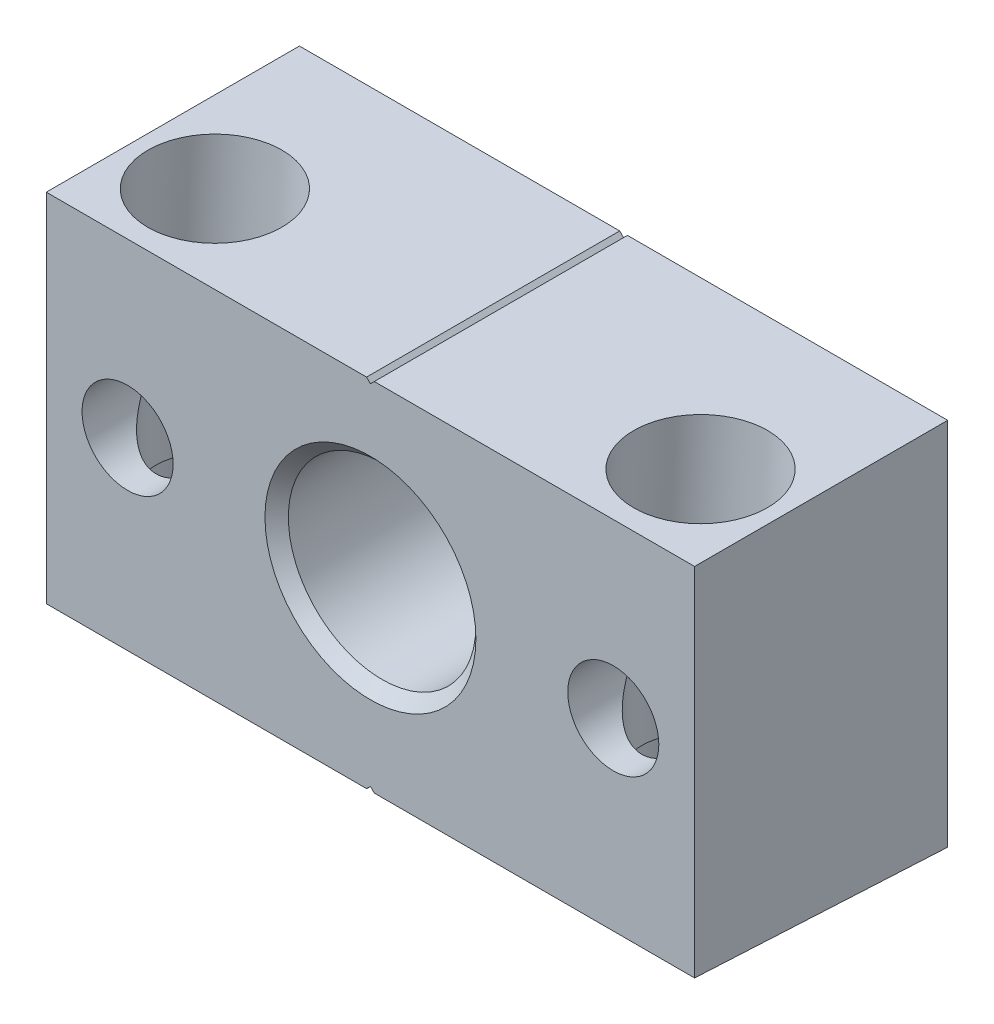
from build123d import *

# Parameters (mm, degrees)
SKETCH1_W          = 64.008
SKETCH1_H          = 36.4998
SKETCH1_R          = 9.2585
SKETCH1_R_2        = 4.4958
EXTRUDE1_DEPTH     = 24.9936
CUT_EXTRUDE1_DEPTH = 65.008
LPATTERN1_COUNT    = 2
LPATTERN1_PITCH    = 47.9552
CHAMFER1_SIZE      = 1.1555
CUT_EXTRUDE2_DEPTH = 25.9936001
CUT_EXTRUDE3_DEPTH = 27.869599175


with BuildPart() as part:
    # Sketch1 → Extrude1 (new body)
    with BuildSketch(Plane.XY):
        with Locations((0, -1.2573)):
            Rectangle(SKETCH1_W, SKETCH1_H)
        Circle(SKETCH1_R, mode=Mode.SUBTRACT)
        with Locations((-23.9776, 0)):
            Circle(SKETCH1_R_2, mode=Mode.SUBTRACT)
        with Locations((23.9776, 0)):
            Circle(SKETCH1_R_2, mode=Mode.SUBTRACT)
    extrude(amount=EXTRUDE1_DEPTH)

    # Sketch2 → Cut-Extrude1 (cut, through all)
    with BuildSketch(Plane(origin=(32.004, 0, 0), x_dir=(0, 0, -1), z_dir=(1, 0, 0))):
        Polygon((0, -19.5072), (-24.9936, -18.197340928), (-24.9936, -19.5072), align=None)
    extrude(amount=-CUT_EXTRUDE1_DEPTH, mode=Mode.SUBTRACT)

    # Sketch3 → Cut-Revolve1 (revolve, cut)
    with BuildSketch(Plane(origin=(-23.9776, 0, 0), x_dir=(0, 0, -1), z_dir=(1, 0, 0)), mode=Mode.PRIVATE) as cut_revolve1_sk:
        Polygon((-10.8966, -18.936133392), (-10.8966, -8.4074), (-12.827, -8.4074), (-12.827, 16.9926), (-17.5006, 16.9926), (-17.5006, -18.936133392), align=None)
    cut_revolve1 = revolve(cut_revolve1_sk.sketch.rotate(Axis((-23.9776, 16.931830478, 17.5006), (0, -1, 0)), 180), axis=Axis((-23.9776, 16.931830478, 17.5006), (0, -1, 0)), mode=Mode.SUBTRACT)  # turned: the seam where the file's is

    # Sketch4 → Cut-Revolve2 (revolve, cut)
    with BuildSketch(Plane(origin=(-23.9776, 0, 0), x_dir=(0, 0, -1), z_dir=(1, 0, 0)), mode=Mode.PRIVATE) as cut_revolve2_sk:
        Polygon((-9.761726171, 16.9926), (-10.313289005, 6.468154162), (-16.908238453, 6.813780817), (-16.356675618, 17.338226655), align=None)
    cut_revolve2 = revolve(cut_revolve2_sk.sketch.rotate(Axis((-23.9776, 21.413064128, 16.143122435), (0, -0.998629535, 0.052335956)), 180), axis=Axis((-23.9776, 21.413064128, 16.143122435), (0, -0.998629535, 0.052335956)), mode=Mode.SUBTRACT)  # turned: the seam where the file's is

    # LPattern1: Cut-Revolve1, Cut-Revolve2 ×2
    with Locations(*[(i * LPATTERN1_PITCH, 0, 0) for i in range(1, LPATTERN1_COUNT)]):
        add(cut_revolve1, mode=Mode.SUBTRACT)
        add(cut_revolve2, mode=Mode.SUBTRACT)

    # Chamfer1
    chamfer1_edges = [part.edges().sort_by_distance(p)[0] for p in [
        (-9.2585, 0, 0),
        (-9.2585, 0, 24.9936),
    ]]
    chamfer(chamfer1_edges, length=CHAMFER1_SIZE)

    # Sketch5 → Cut-Extrude2 (cut, through all)
    with BuildSketch(Plane(origin=(0, 0, 0), x_dir=(-1, 0, 0), z_dir=(0, 0, -1))):
        Polygon((-0.381, 16.9926), (0, 16.6116), (0.381, 16.9926), align=None)
    extrude(amount=-CUT_EXTRUDE2_DEPTH, mode=Mode.SUBTRACT)

    # Sketch6 → Cut-Extrude3 (cut, through all)
    with BuildSketch(Plane(origin=(0, -0.053431241, -1.019528819), x_dir=(-1, 0, 0), z_dir=(0, -0.052335956, -0.998629535))):
        Polygon((0.381, -19.48046606), (0, -19.09946606), (-0.381, -19.48046606), align=None)
    extrude(amount=-CUT_EXTRUDE3_DEPTH, mode=Mode.SUBTRACT)


solid = part.part
